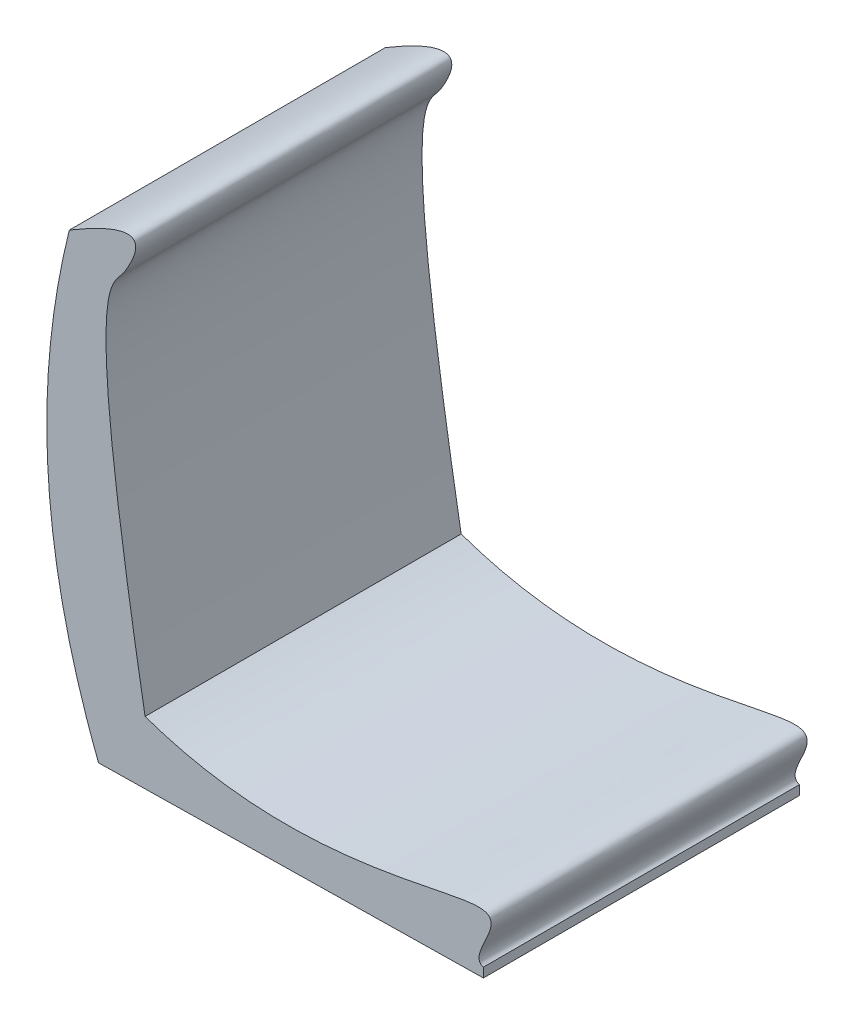
from build123d import *

# Parameters (mm, degrees)
BOSS_EXTRUDE1_DEPTH = 170
BOSS_EXTRUDE5_DEPTH = 340


with BuildPart() as part:
    # Sketch1 → Boss-Extrude1 (new body, symmetric)
    with BuildSketch(Plane.XY):
        with BuildLine():
            Line((-43.242034692, 4.88357889), (363.769485966, 11.336200559))
            Line((363.769485966, 11.336200559), (363.928002632, 1.337457015))
            Line((363.928002632, 1.337457015), (-50.091647845, -5.226269151))
            add(Edge.make_bspline(
                [(-81.516854508, 475.367364152), (-82.781115884, 470.304932433), (-85.22154778, 460.13815021), (-89.692446693, 439.866979621), (-94.538479949, 414.539481529), (-99.156253872, 384.1992794), (-103.718426393, 343.806201554), (-106.427442665, 293.437675818), (-104.885012492, 233.204575035), (-98.54882656, 173.195950206), (-89.277227619, 123.388994876), (-79.467108737, 83.667694933), (-70.917280487, 53.945962518), (-62.789233981, 29.216851203), (-56.594331301, 11.966144888), (-52.879677882, 2.069177856), (-51.020998123, -2.786789385), (-50.091647845, -5.226269151)],
                knots=[0, 0, 0, 0, 0.031693726, 0.063387453, 0.126774906, 0.190162358, 0.253549811, 0.380324717, 0.507099622, 0.633874528, 0.760649433, 0.824036886, 0.887424339, 0.950811792, 0.982505518, 0.998352381, 1.014199244, 1.014199244, 1.014199244, 1.014199244], degree=3))
            Line((-81.516854508, 475.367364152), (-71.814822602, 472.944436812))
            add(Edge.make_bspline(
                [(-71.814822602, 472.944436812), (-131.107019076, 235.52304468), (-43.242034692, 4.88357889)],
                knots=[0, 0, 0, 1, 1, 1], degree=2))
        make_face()
    extrude(amount=BOSS_EXTRUDE1_DEPTH, both=True)

    # Sketch3 → Boss-Extrude5 (add)
    with BuildSketch(Plane(origin=(0, 0, -170), x_dir=(-1, 0, 0), z_dir=(0, 0, -1))):
        with BuildLine():
            Line((-363.769485966, 11.336200559), (50.129751592, 4.614264228))
            add(Edge.make_bspline(
                [(50.129751592, 4.614264228), (131.486193382, 236.049810492), (81.516854508, 475.367364152)],
                knots=[0, 0, 0, 1, 1, 1], degree=2))
            add(Edge.make_bspline(
                [(81.516854508, 475.367364152), (-9.814220512, 530.127267376), (16.949445549, 472.968223295), (35.710932815, 447.292156657), (64.280513926, 428.678264595), (0, 63.019406503)],
                knots=[0, 0, 0, 0, 0.243320458, 0.343320458, 1, 1, 1, 1], degree=3))
            add(Edge.make_bspline(
                [(-363.769485966, 11.336200559), (-344.876156314, 18.239298533), (-451.441883383, 117.775676676), (-163.678009085, 5.379194053), (0, 63.019406503)],
                knots=[0, 0, 0, 0, 0.394178144, 0.872405199, 0.872405199, 0.872405199, 0.872405199], degree=3))
        make_face()
    extrude(amount=-BOSS_EXTRUDE5_DEPTH)


solid = part.part
